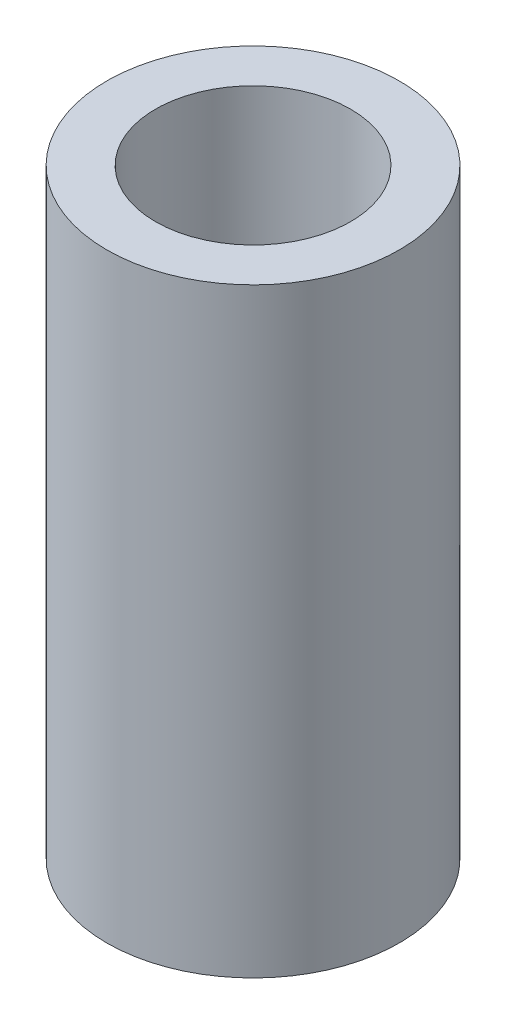
from build123d import *

# Parameters (mm, degrees)
SKETCH2_R           = 1.95
SKETCH2_R_2         = 1.3
BOSS_EXTRUDE1_DEPTH = 8


with BuildPart() as part:
    # Sketch2 → Boss-Extrude1 (new body)
    with BuildSketch(Plane(origin=(0, 0, 0), x_dir=(1, 0, 0), z_dir=(0, 1, 0))):
        Circle(SKETCH2_R)
        Circle(SKETCH2_R_2, mode=Mode.SUBTRACT)
    extrude(amount=BOSS_EXTRUDE1_DEPTH)


solid = part.part
